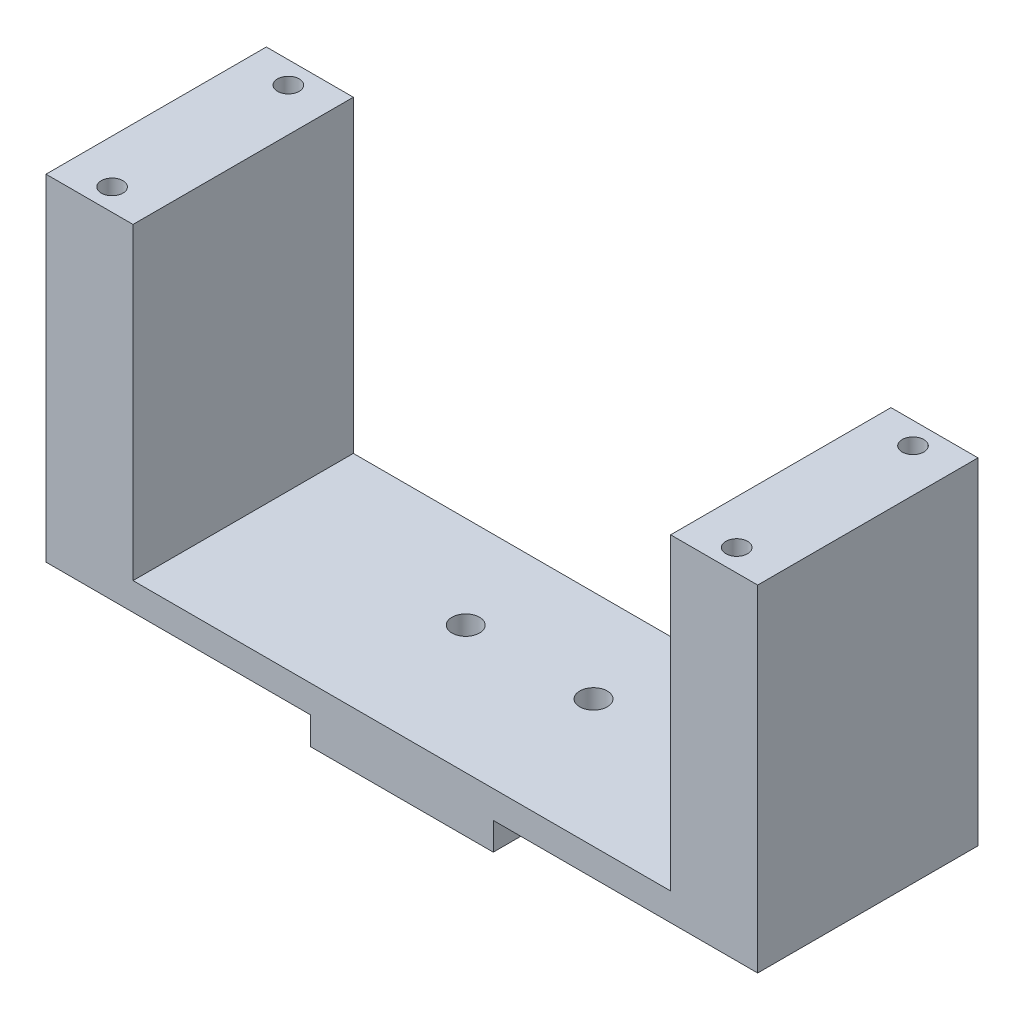
from build123d import *

# Parameters (mm, degrees)
SKETCH1_W           = 69.85
SKETCH1_H           = 25.4
BOSS_EXTRUDE1_DEPTH = 3.175
SKETCH2_W           = 3.937
SKETCH2_H           = 25.4
BOSS_EXTRUDE2_DEPTH = 35.56
SKETCH6_R           = 1.5875
CUT_EXTRUDE1_DEPTH  = 35.56
SKETCH10_W          = 25.4
SKETCH10_H          = 38.735
BOSS_EXTRUDE3_DEPTH = 6.096
SKETCH11_W          = 25.4
SKETCH11_H          = 38.735
BOSS_EXTRUDE4_DEPTH = 6.096
SKETCH14_R          = 1.25
CUT_EXTRUDE2_DEPTH  = 20.574
SKETCH15_W          = 21.082
SKETCH15_H          = 25.4
SKETCH15_R          = 1.5875
BOSS_EXTRUDE6_DEPTH = 3.175


with BuildPart() as part:
    # Sketch1 → Boss-Extrude1 (new body)
    with BuildSketch(Plane(origin=(0, 0, 0), x_dir=(1, 0, 0), z_dir=(0, 1, 0))):
        with Locations((3.81330156, 4.308535529)):
            Rectangle(SKETCH1_W, SKETCH1_H)
    extrude(amount=BOSS_EXTRUDE1_DEPTH)

    # Sketch2 → Boss-Extrude2 (add)
    with BuildSketch(Plane(origin=(0, 3.175, 0), x_dir=(1, 0, 0), z_dir=(0, 1, 0))):
        with Locations((-29.14319844, 4.308535529)):
            Rectangle(SKETCH2_W, SKETCH2_H)
        with Locations((36.76980156, 4.308535529)):
            Rectangle(SKETCH2_W, SKETCH2_H)
    extrude(amount=BOSS_EXTRUDE2_DEPTH)

    # Sketch6 → Cut-Extrude1 (cut)
    with BuildSketch(Plane.XZ):
        with Locations((-3.55269844, -6.340535529)):
            Circle(SKETCH6_R)
        with Locations((11.17930156, -6.340535529)):
            Circle(SKETCH6_R)
    extrude(amount=-CUT_EXTRUDE1_DEPTH, mode=Mode.SUBTRACT)

    # Sketch10 → Boss-Extrude3 (add)
    with BuildSketch(Plane.ZY.offset(31.11169844)):
        with Locations((-4.308535529, 19.3675)):
            Rectangle(SKETCH10_W, SKETCH10_H)
    extrude(amount=BOSS_EXTRUDE3_DEPTH)

    # Sketch11 → Boss-Extrude4 (add)
    with BuildSketch(Plane(origin=(38.73830156, 0, 0), x_dir=(0, 0, -1), z_dir=(1, 0, 0))):
        with Locations((4.308535529, 19.3675)):
            Rectangle(SKETCH11_W, SKETCH11_H)
    extrude(amount=BOSS_EXTRUDE4_DEPTH)

    # Sketch14 → Cut-Extrude2 (cut)
    with BuildSketch(Plane(origin=(0, 38.735, 0), x_dir=(1, 0, 0), z_dir=(0, 1, 0))):
        with Locations((-32.12769844, 14.468535529)):
            Circle(SKETCH14_R)
        with Locations((-32.12769844, -5.851464471)):
            Circle(SKETCH14_R)
        with Locations((39.88130156, 14.468535529)):
            Circle(SKETCH14_R)
        with Locations((39.88130156, -5.851464471)):
            Circle(SKETCH14_R)
    extrude(amount=-CUT_EXTRUDE2_DEPTH, mode=Mode.SUBTRACT)

    # Sketch15 → Boss-Extrude6 (add)
    with BuildSketch(Plane.XZ):
        with Locations((3.81330156, -4.308535529)):
            Rectangle(SKETCH15_W, SKETCH15_H)
        with Locations((-3.55269844, -6.340535529)):
            Circle(SKETCH15_R, mode=Mode.SUBTRACT)
        with Locations((11.17930156, -6.340535529)):
            Circle(SKETCH15_R, mode=Mode.SUBTRACT)
    extrude(amount=BOSS_EXTRUDE6_DEPTH)


solid = part.part
